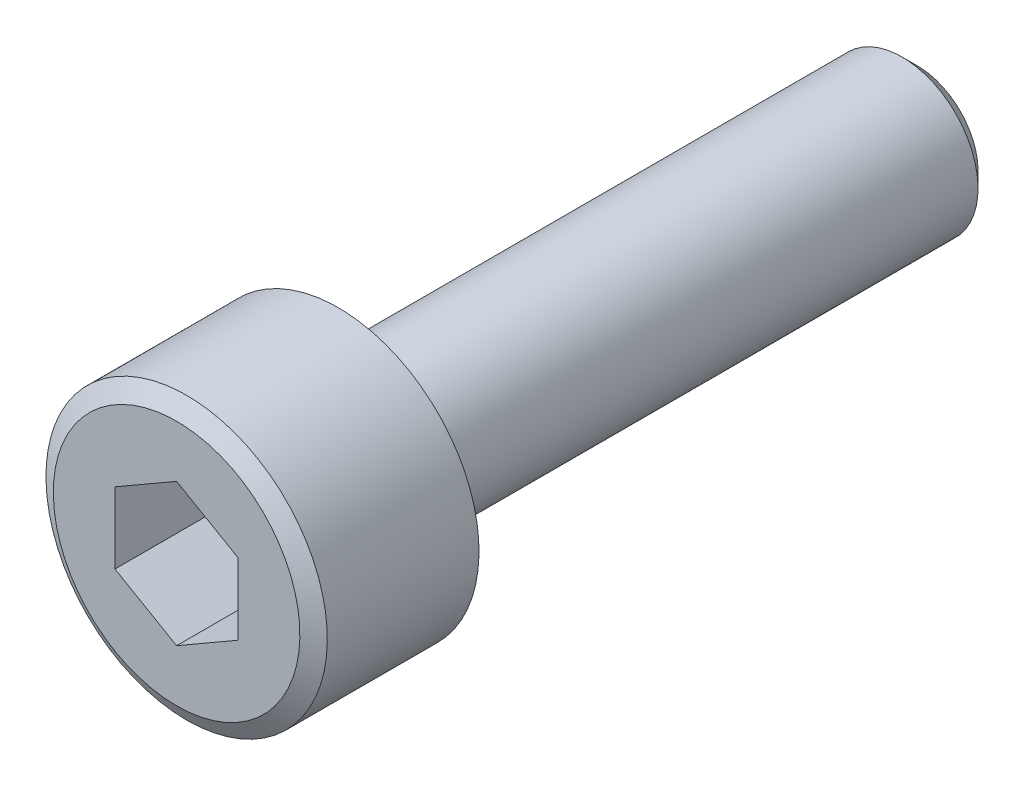
from build123d import *

# Parameters (mm, degrees)
CHAMFER1_SIZE      = 0.8
CUT_EXTRUDE1_DEPTH = 6


with BuildPart() as part:
    # Sketch1 → Revolve1 (revolve)
    with BuildSketch(Plane(origin=(0, 0, 0), x_dir=(0, 0, -1), z_dir=(1, 0, 0))):
        Polygon((0, 0), (0, 6.5), (0.53, 7.417986928), (8.53, 7.417986928), (9.06, 6.5), (9.06, 4), (39.06, 4), (39.06, 0), align=None)
    revolve(axis=Axis((0, 0, 0), (0, 0, -1)))

    # Chamfer1
    chamfer1_edges = [part.edges().sort_by_distance(p)[0] for p in [
        (0, -4, -39.06),
    ]]
    chamfer(chamfer1_edges, length=CHAMFER1_SIZE)

    # Sketch2 → Cut-Extrude1 (cut)
    with BuildSketch(Plane.XY):
        Polygon((-3.25, 1.876388375), (-3.25, -1.876388375), (0, -3.75277675), (3.25, -1.876388375), (3.25, 1.876388375), (0, 3.75277675), align=None)
    extrude(amount=-CUT_EXTRUDE1_DEPTH, mode=Mode.SUBTRACT)

    # Sketch3 → Cut-Revolve2 (revolve, cut)
    with BuildSketch(Plane(origin=(0, 0, 0), x_dir=(0, 0, -1), z_dir=(1, 0, 0))):
        Polygon((6, 0), (6, 3.75277675), (8.166666667, 0), align=None)
    revolve(axis=Axis((0, 0, 0), (0, 0, -1)), mode=Mode.SUBTRACT)


solid = part.part
